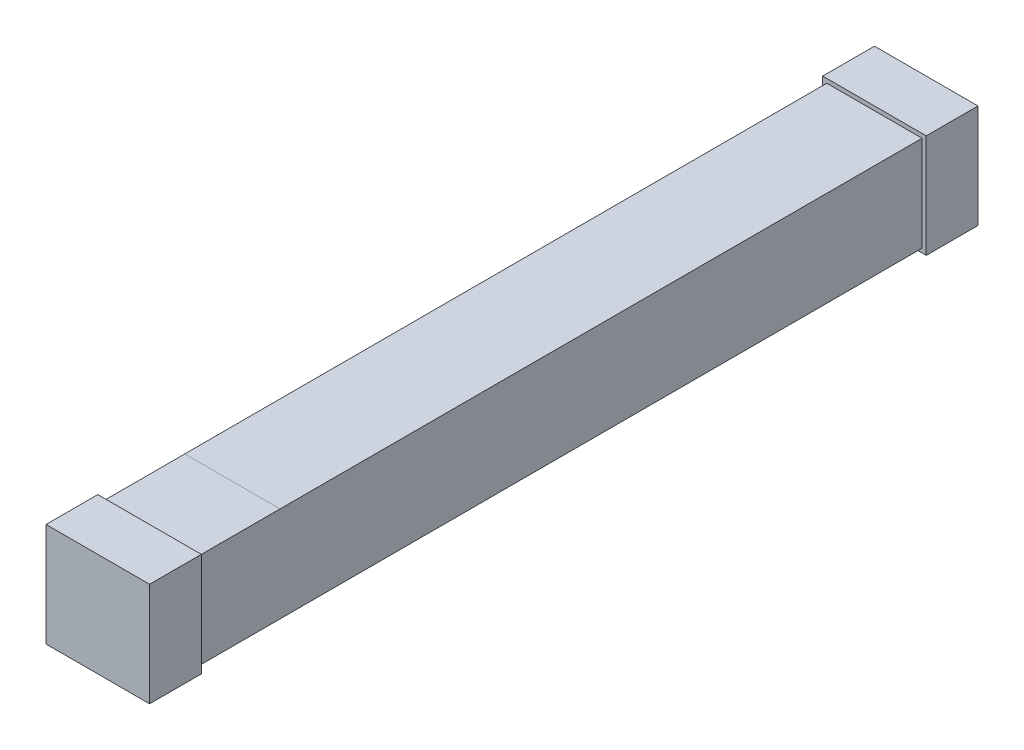
from build123d import *

# Parameters (mm, degrees)
SKETCH1_W           = 0.92
SKETCH1_H           = 0.92
BOSS_EXTRUDE1_DEPTH = 3.5
SKETCH2_W           = 1
SKETCH2_H           = 1
BOSS_EXTRUDE2_DEPTH = 0.5


with BuildPart() as part:
    # Sketch1 → Boss-Extrude1 (new body, symmetric)
    with BuildSketch(Plane.XY):
        with Locations((0, 0.5)):
            Rectangle(SKETCH1_W, SKETCH1_H)
    extrude(amount=BOSS_EXTRUDE1_DEPTH, both=True)

    # Sketch2 → Boss-Extrude2 (add)
    with BuildSketch(Plane.XY.offset(3.5)):
        with Locations((0, 0.5)):
            Rectangle(SKETCH2_W, SKETCH2_H)
    boss_extrude2 = extrude(amount=BOSS_EXTRUDE2_DEPTH)

    # Mirror1: Boss-Extrude2 across plane
    add(boss_extrude2.mirror(Plane.XY))


solid = part.part
